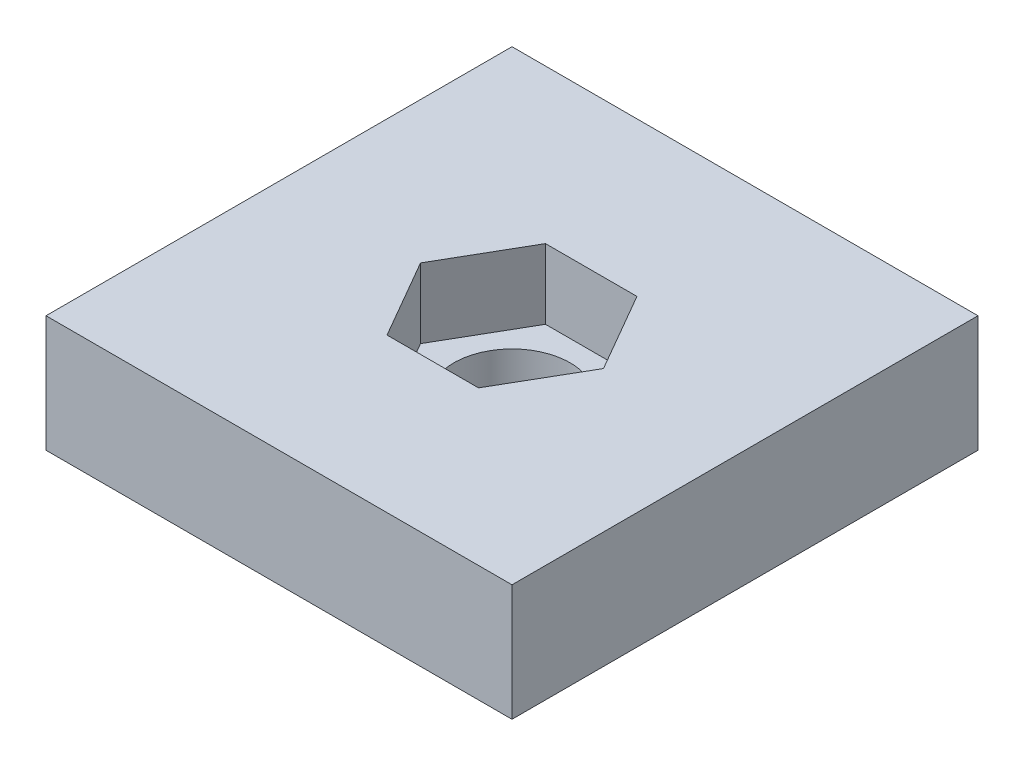
from build123d import *

# Parameters (mm, degrees)
SKETCH1_W           = 20
SKETCH1_H           = 20
BOSS_EXTRUDE1_DEPTH = 5
CUT_EXTRUDE1_DEPTH  = 3
SKETCH4_R           = 2.5
CUT_EXTRUDE2_DEPTH  = 3


with BuildPart() as part:
    # Sketch1 → Boss-Extrude1 (new body)
    with BuildSketch(Plane(origin=(0, 0, 0), x_dir=(1, 0, 0), z_dir=(0, 1, 0))):
        Rectangle(SKETCH1_W, SKETCH1_H)
    extrude(amount=BOSS_EXTRUDE1_DEPTH)

    # Sketch3 → Cut-Extrude1 (cut)
    with BuildSketch(Plane(origin=(0, 5, 0), x_dir=(1, 0, 0), z_dir=(0, 1, 0))):
        Polygon((3.92598183, 0), (1.962990915, 3.4), (-1.962990915, 3.4), (-3.92598183, 0), (-1.962990915, -3.4), (1.962990915, -3.4), align=None)
    extrude(amount=-CUT_EXTRUDE1_DEPTH, mode=Mode.SUBTRACT)

    # Sketch4 → Cut-Extrude2 (cut, through all)
    with BuildSketch(Plane(origin=(0, 2, 0), x_dir=(1, 0, 0), z_dir=(0, 1, 0))):
        Circle(SKETCH4_R)
    extrude(amount=-CUT_EXTRUDE2_DEPTH, mode=Mode.SUBTRACT)


solid = part.part
